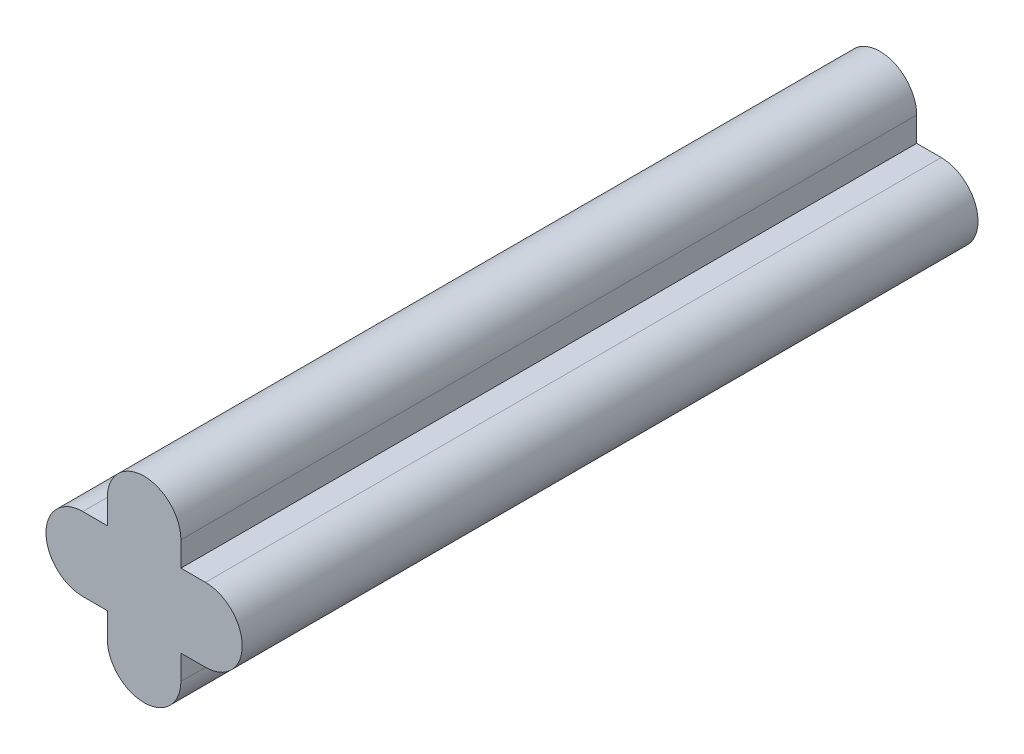
from build123d import *

# Parameters (mm, degrees)
BOSS_EXTRUDE1_DEPTH = 30


with BuildPart() as part:
    # Sketch1 → Boss-Extrude1 (new body)
    with BuildSketch(Plane.XY):
        with BuildLine():
            Line((-2.5, 1.5), (-1.5, 1.5))
            Line((-1.5, 1.5), (-1.5, 2.5))
            ThreePointArc((-1.5, 2.5), (0, 4), (1.5, 2.5))
            Line((1.5, 2.5), (1.5, 1.5))
            Line((1.5, 1.5), (2.5, 1.5))
            ThreePointArc((2.5, 1.5), (4, 0), (2.5, -1.5))
            Line((2.5, -1.5), (1.5, -1.5))
            Line((1.5, -1.5), (1.5, -2.5))
            ThreePointArc((1.5, -2.5), (0, -4), (-1.5, -2.5))
            Line((-1.5, -2.5), (-1.5, -1.5))
            Line((-1.5, -1.5), (-2.5, -1.5))
            ThreePointArc((-2.5, -1.5), (-4, 0), (-2.5, 1.5))
        make_face()
    extrude(amount=BOSS_EXTRUDE1_DEPTH)


solid = part.part
